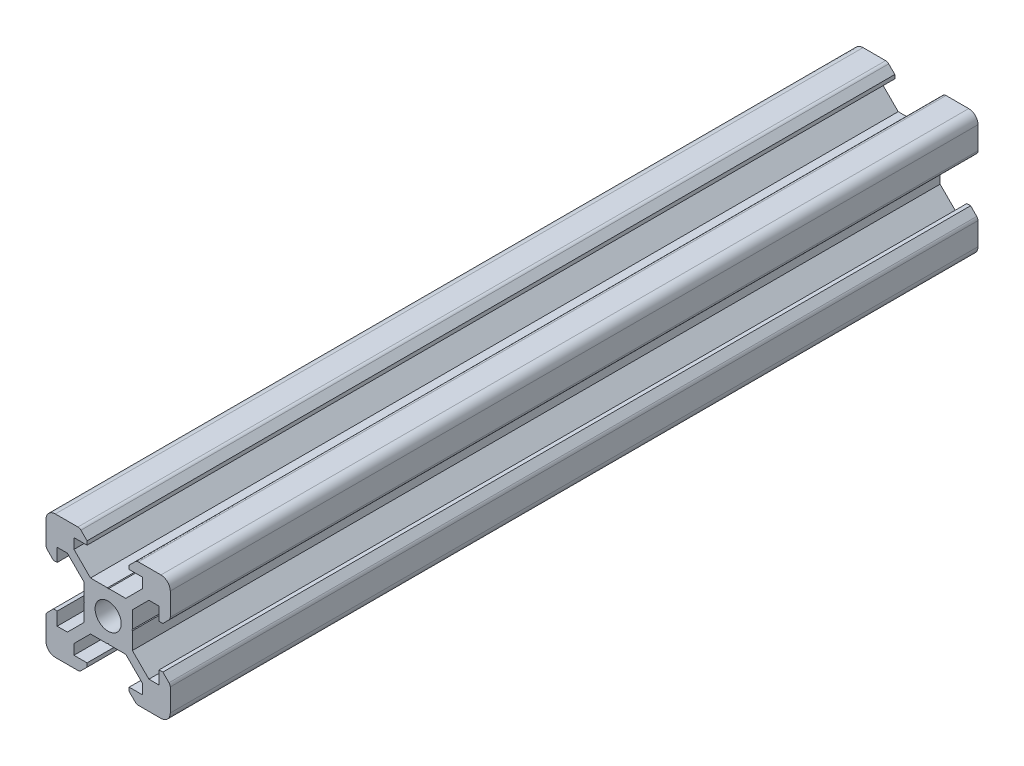
from build123d import *

# Parameters (mm, degrees)
SKETCH1_R           = 2.1
BOSS_EXTRUDE1_DEPTH = 130


with BuildPart() as part:
    # Sketch1 → Boss-Extrude1 (new body)
    with BuildSketch(Plane.XY):
        with BuildLine():
            Line((-8.5, 10), (-4.862792737, 10))
            ThreePointArc((-4.862792737, 10), (-4.598292737, 9.947387679), (-4.374060464, 9.797560464))
            Line((-4.374060464, 9.797560464), (-3.3865, 8.81))
            Line((-3.3865, 8.81), (-3.3865, 8.2))
            Line((-3.3865, 8.2), (-5.5, 8.2))
            Line((-5.5, 8.2), (-5.5, 6.561))
            Line((-5.5, 6.561), (-2.8395, 3.9005))
            Line((-2.8395, 3.9005), (-0.1, 3.9005))
            Line((-0.1, 3.9005), (0, 3.8005))
            Line((0, 3.8005), (0.1, 3.9005))
            Line((0.1, 3.9005), (2.8395, 3.9005))
            Line((2.8395, 3.9005), (5.5, 6.561))
            Line((5.5, 6.561), (5.5, 8.2))
            Line((5.5, 8.2), (3.3865, 8.2))
            Line((3.3865, 8.2), (3.3865, 8.81))
            Line((3.3865, 8.81), (4.374060464, 9.797560464))
            ThreePointArc((4.374060464, 9.797560464), (4.598292737, 9.947387679), (4.862792737, 10))
            Line((4.862792737, 10), (8.5, 10))
            ThreePointArc((8.5, 10), (9.560660172, 9.560660172), (10, 8.5))
            Line((10, 8.5), (10, 4.862792737))
            ThreePointArc((10, 4.862792737), (9.947387679, 4.598292737), (9.797560464, 4.374060464))
            Line((9.797560464, 4.374060464), (8.81, 3.3865))
            Line((8.81, 3.3865), (8.2, 3.3865))
            Line((8.2, 3.3865), (8.2, 5.5))
            Line((8.2, 5.5), (6.561, 5.5))
            Line((6.561, 5.5), (3.9005, 2.8395))
            Line((3.9005, 2.8395), (3.9005, 0.1))
            Line((3.9005, 0.1), (3.8005, 0))
            Line((3.8005, 0), (3.9005, -0.1))
            Line((3.9005, -0.1), (3.9005, -2.8395))
            Line((3.9005, -2.8395), (6.561, -5.5))
            Line((6.561, -5.5), (8.2, -5.5))
            Line((8.2, -5.5), (8.2, -3.3865))
            Line((8.2, -3.3865), (8.81, -3.3865))
            Line((8.81, -3.3865), (9.797560464, -4.374060464))
            ThreePointArc((9.797560464, -4.374060464), (9.947387679, -4.598292737), (10, -4.862792737))
            Line((10, -4.862792737), (10, -8.5))
            ThreePointArc((10, -8.5), (9.560660172, -9.560660172), (8.5, -10))
            Line((8.5, -10), (4.862792737, -10))
            ThreePointArc((4.862792737, -10), (4.598292737, -9.947387679), (4.374060464, -9.797560464))
            Line((4.374060464, -9.797560464), (3.3865, -8.81))
            Line((3.3865, -8.81), (3.3865, -8.2))
            Line((3.3865, -8.2), (5.5, -8.2))
            Line((5.5, -8.2), (5.5, -6.561))
            Line((5.5, -6.561), (2.8395, -3.9005))
            Line((2.8395, -3.9005), (0.1, -3.9005))
            Line((0.1, -3.9005), (0, -3.8005))
            Line((0, -3.8005), (-0.1, -3.9005))
            Line((-0.1, -3.9005), (-2.8395, -3.9005))
            Line((-2.8395, -3.9005), (-5.5, -6.561))
            Line((-5.5, -6.561), (-5.5, -8.2))
            Line((-5.5, -8.2), (-3.3865, -8.2))
            Line((-3.3865, -8.2), (-3.3865, -8.81))
            Line((-3.3865, -8.81), (-4.374060464, -9.797560464))
            ThreePointArc((-4.374060464, -9.797560464), (-4.598292737, -9.947387679), (-4.862792737, -10))
            Line((-4.862792737, -10), (-8.5, -10))
            ThreePointArc((-8.5, -10), (-9.560660172, -9.560660172), (-10, -8.5))
            Line((-10, -8.5), (-10, -4.862792737))
            ThreePointArc((-10, -4.862792737), (-9.947387679, -4.598292737), (-9.797560464, -4.374060464))
            Line((-9.797560464, -4.374060464), (-8.81, -3.3865))
            Line((-8.81, -3.3865), (-8.2, -3.3865))
            Line((-8.2, -3.3865), (-8.2, -5.5))
            Line((-8.2, -5.5), (-6.561, -5.5))
            Line((-6.561, -5.5), (-3.9005, -2.8395))
            Line((-3.9005, -2.8395), (-3.9005, -0.1))
            Line((-3.9005, -0.1), (-3.8005, 0))
            Line((-3.8005, 0), (-3.9005, 0.1))
            Line((-3.9005, 0.1), (-3.9005, 2.8395))
            Line((-3.9005, 2.8395), (-6.561, 5.5))
            Line((-6.561, 5.5), (-8.2, 5.5))
            Line((-8.2, 5.5), (-8.2, 3.3865))
            Line((-8.2, 3.3865), (-8.81, 3.3865))
            Line((-8.81, 3.3865), (-9.797560464, 4.374060464))
            ThreePointArc((-9.797560464, 4.374060464), (-9.947387679, 4.598292737), (-10, 4.862792737))
            Line((-10, 4.862792737), (-10, 8.5))
            ThreePointArc((-10, 8.5), (-9.560660172, 9.560660172), (-8.5, 10))
        make_face()
        Circle(SKETCH1_R, mode=Mode.SUBTRACT)
    extrude(amount=BOSS_EXTRUDE1_DEPTH)


solid = part.part
